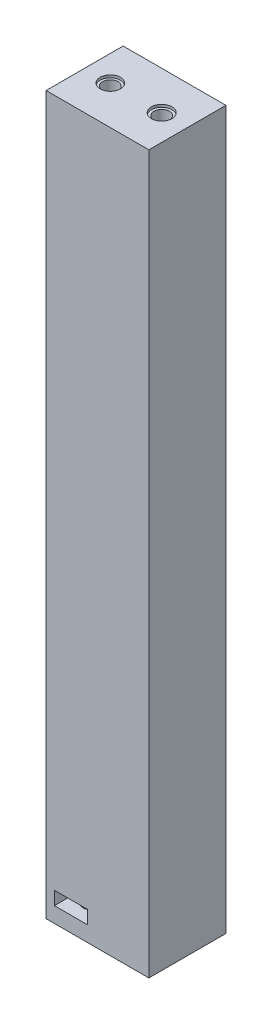
from build123d import *

# Parameters (mm, degrees)
BOSS_EXTRUDE1_DEPTH = 2.6
SKETCH2_R           = 1.5
BOSS_EXTRUDE2_DEPTH = 3
SKETCH6_R           = 1.5
BOSS_EXTRUDE3_DEPTH = 134
SKETCH8_R           = 1.5
CUT_EXTRUDE1_DEPTH  = 19.5
SKETCH9_R           = 1.5
CUT_EXTRUDE2_DEPTH  = 7
SKETCH10_R          = 1.965
SKETCH10_R_2        = 2
CUT_EXTRUDE4_DEPTH  = 0.5


with BuildPart() as part:
    # Sketch1 → Boss-Extrude1 (new body)
    with BuildSketch(Plane(origin=(0, 0, 0), x_dir=(1, 0, 0), z_dir=(0, 1, 0))):
        Polygon((-8.2, -7.407073571), (-8.2, -3.5), (-8.2, 0.15), (-5, 0.15), (-1.8, 0.15), (-1.8, -3.5), (-1.8, -7.407073571), (10.185852857, -7.407073571), (10.185852857, 3.5), (10.185852857, 7.592926429), (8.2, 7.592926429), (8.2, 3.5), (8.2, -0.15), (5, -0.15), (1.8, -0.15), (1.8, 3.5), (1.8, 7.592926429), (-9.814147143, 7.592926429), (-9.814147143, -7.407073571), align=None)
    extrude(amount=BOSS_EXTRUDE1_DEPTH)

    # Sketch2 → Boss-Extrude2 (add)
    with BuildSketch(Plane.XZ):
        Polygon((-8.2, 7.407073571), (-9.814147143, 7.407073571), (-9.814147143, -7.592926429), (1.8, -7.592926429), (1.8, -3.5), (1.8, 0.15), (5, 0.15), (8.2, 0.15), (8.2, -3.5), (8.2, -7.592926429), (10.185852857, -7.592926429), (10.185852857, -3.5), (10.185852857, 7.407073571), (-1.8, 7.407073571), (-1.8, 3.5), (-1.8, -0.15), (-5, -0.15), (-8.2, -0.15), (-8.2, 3.5), align=None)
        Polygon((1.8, -3.5), (1.8, -7.592926429), (5.185852857, -7.592926429), (8.2, -7.592926429), (8.2, -3.5), (8.2, 0.15), (5, 0.15), (1.8, 0.15), align=None)
        with Locations((5, -3.5)):
            Circle(SKETCH2_R, mode=Mode.SUBTRACT)
        Polygon((-1.8, 7.407073571), (-8.2, 7.407073571), (-8.2, 3.5), (-8.2, -0.15), (-5, -0.15), (-1.8, -0.15), (-1.8, 3.5), align=None)
        with Locations((-5, 3.5)):
            Circle(SKETCH2_R, mode=Mode.SUBTRACT)
    extrude(amount=BOSS_EXTRUDE2_DEPTH)

    # Sketch6 → Boss-Extrude3 (add)
    with BuildSketch(Plane(origin=(0, 2.6, 0), x_dir=(1, 0, 0), z_dir=(0, 1, 0))):
        Polygon((-8.2, -3.5), (-8.2, -7.407073571), (-1.8, -7.407073571), (-1.8, -3.5), (-1.8, 0.15), (-5, 0.15), (-8.2, 0.15), align=None)
        with Locations((-5, -3.5)):
            Circle(SKETCH6_R, mode=Mode.SUBTRACT)
        Polygon((5.185852857, 7.592926429), (1.8, 7.592926429), (1.8, 3.5), (1.8, -0.15), (5, -0.15), (8.2, -0.15), (8.2, 3.5), (8.2, 7.592926429), align=None)
        with Locations((5, 3.5)):
            Circle(SKETCH6_R, mode=Mode.SUBTRACT)
        Polygon((1.8, 7.592926429), (-9.814147143, 7.592926429), (-9.814147143, -7.407073571), (-8.2, -7.407073571), (-8.2, -3.5), (-8.2, 0.15), (-5, 0.15), (-1.8, 0.15), (-1.8, -3.5), (-1.8, -7.407073571), (10.185852857, -7.407073571), (10.185852857, 3.5), (10.185852857, 7.592926429), (8.2, 7.592926429), (8.2, 3.5), (8.2, -0.15), (5, -0.15), (1.8, -0.15), (1.8, 3.5), align=None)
        with Locations((-5, -3.5)):
            Circle(SKETCH6_R)
        with Locations((5, 3.5)):
            Circle(SKETCH6_R)
    extrude(amount=BOSS_EXTRUDE3_DEPTH)

    # Sketch8 → Cut-Extrude1 (cut)
    with BuildSketch(Plane.XZ.offset(3)):
        with Locations((-5, 3.5)):
            Circle(SKETCH8_R)
        with Locations((5, -3.5)):
            Circle(SKETCH8_R)
    extrude(amount=-CUT_EXTRUDE1_DEPTH, mode=Mode.SUBTRACT)

    # Sketch9 → Cut-Extrude2 (cut)
    with BuildSketch(Plane(origin=(0, 136.6, 0), x_dir=(1, 0, 0), z_dir=(0, 1, 0))):
        with Locations((-4.814147143, 0.092926429)):
            Circle(SKETCH9_R)
        with Locations((5.185852857, 0.092926429)):
            Circle(SKETCH9_R)
    extrude(amount=-CUT_EXTRUDE2_DEPTH, mode=Mode.SUBTRACT)

    # Sketch10 → Cut-Extrude4 (cut)
    with BuildSketch(Plane(origin=(0, 136.6, 0), x_dir=(1, 0, 0), z_dir=(0, 1, 0))):
        with Locations((-4.814147143, 0.092926429)):
            Circle(SKETCH10_R)
        with Locations((5.185852857, 0.092926429)):
            Circle(SKETCH10_R_2)
    extrude(amount=-CUT_EXTRUDE4_DEPTH, mode=Mode.SUBTRACT)


solid = part.part
